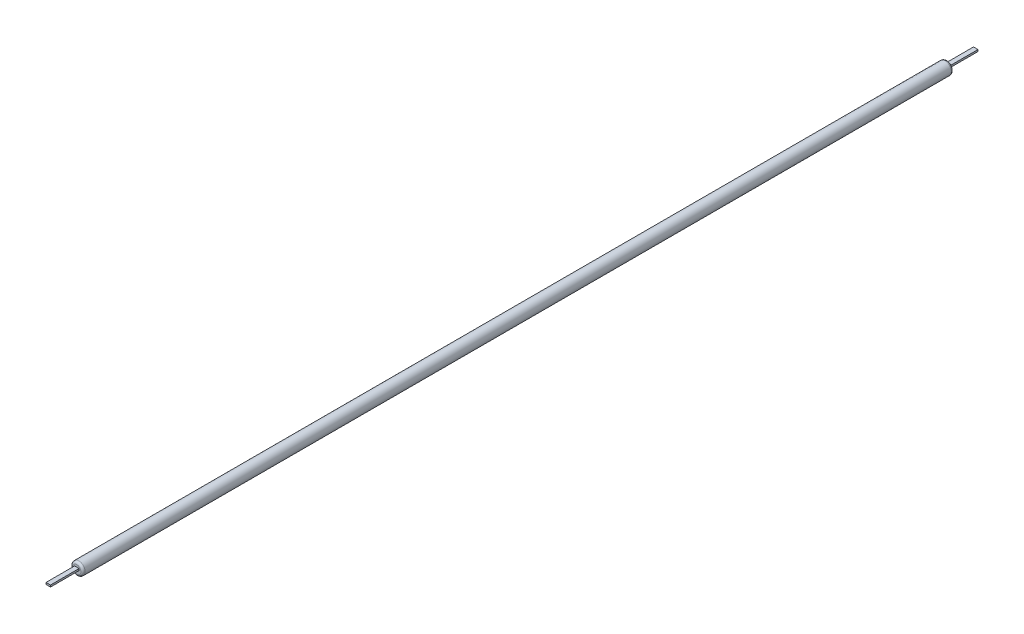
from build123d import *

# Parameters (mm, degrees)
ESQUISSE1_R             = 0.875
BOSS_EXTRU_1_DEPTH      = 122
ESQUISSE2_W             = 0.62970299
ESQUISSE2_H             = 8
BOSS_EXTRU_2_DEPTH      = 0.25
CONG_1_R                = 0.3
ENL_V_MAT_EXTRU_1_DEPTH = 0.06


with BuildPart() as part:
    # Esquisse1 → Boss.-Extru.1 (new body)
    with BuildSketch(Plane.XY):
        Circle(ESQUISSE1_R)
    extrude(amount=BOSS_EXTRU_1_DEPTH)

    # Esquisse2 → Boss.-Extru.2 (add)
    with BuildSketch(Plane(origin=(0, 0, 0), x_dir=(1, 0, 0), z_dir=(0, 1, 0))):
        Rectangle(ESQUISSE2_W, ESQUISSE2_H)
        with Locations((0, -122)):
            Rectangle(ESQUISSE2_W, ESQUISSE2_H)
    extrude(amount=BOSS_EXTRU_2_DEPTH)

    # Congé1
    cong_1_edges = [part.edges().sort_by_distance(p)[0] for p in [
        (-0.875, 0, 0),
        (-0.875, 0, 122),
    ]]
    fillet(cong_1_edges, radius=CONG_1_R)

    # Esquisse3 → Enlèv. mat.-Extru.1 (cut)
    with BuildSketch(Plane.XZ):
        Polygon((-0.023732379, -2.988428768), (-0.023732379, -2.840992871), (0.021139416, -2.840992871), (0.021139416, -2.988428768), (0.168575313, -2.988428768), (0.168575313, -3.033300563), (0.021139416, -3.033300563), (0.021139416, -3.18073646), (-0.023732379, -3.18073646), (-0.023732379, -3.033300563), (-0.171168277, -3.033300563), (-0.171168277, -2.988428768), align=None)
    extrude(amount=-ENL_V_MAT_EXTRU_1_DEPTH, mode=Mode.SUBTRACT)


solid = part.part
